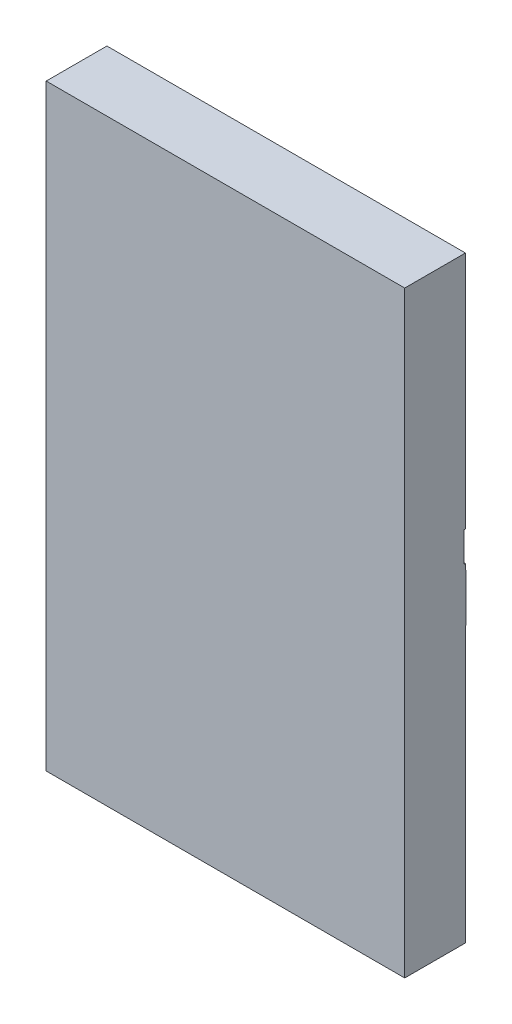
from build123d import *

# Parameters (mm, degrees)
SKETCH1_W           = 3
SKETCH1_H           = 5
BASE_EXTRUDE_DEPTH  = 0.508
SKETCH2_W           = 0.01
SKETCH2_H           = 0.25
CUT_EXTRUDE1_DEPTH  = 4
SKETCH3_W           = 0.003
SKETCH3_H           = 0.4
BOSS_EXTRUDE2_DEPTH = 3
SKETCH16_W          = 2
SKETCH16_H          = 0.5
BOSS_EXTRUDE3_DEPTH = 0.097
SKETCH17_W          = 0.005
SKETCH17_H          = 0.01
CUT_EXTRUDE2_DEPTH  = 4


with BuildPart() as part:
    # Sketch1 → Base-Extrude (new body)
    with BuildSketch(Plane.XY):
        with Locations((1.5, 2.5)):
            Rectangle(SKETCH1_W, SKETCH1_H)
    extrude(amount=BASE_EXTRUDE_DEPTH)

    # Sketch2 → Cut-Extrude1 (cut, through all)
    with BuildSketch(Plane(origin=(3, 0, 0), x_dir=(0, 0, -1), z_dir=(1, 0, 0))):
        with Locations((-0.005, 2.875)):
            Rectangle(SKETCH2_W, SKETCH2_H)
    extrude(amount=-CUT_EXTRUDE1_DEPTH, mode=Mode.SUBTRACT)

    # Sketch3 → Boss-Extrude2 (add)
    with BuildSketch(Plane(origin=(3, 0, 0), x_dir=(0, 0, -1), z_dir=(1, 0, 0))):
        with Locations((0.0015, 2.5)):
            Rectangle(SKETCH3_W, SKETCH3_H)
    extrude(amount=-BOSS_EXTRUDE2_DEPTH)

    # Sketch16 → Boss-Extrude3 (add)
    with BuildSketch(Plane(origin=(0, 0, -0.003), x_dir=(-1, 0, 0), z_dir=(0, 0, -1))):
        with Locations((-1.001, 2.5)):
            Rectangle(SKETCH16_W, SKETCH16_H)
    extrude(amount=BOSS_EXTRUDE3_DEPTH)

    # Sketch17 → Cut-Extrude2 (cut, through all)
    with BuildSketch(Plane.ZY):
        with Locations((-0.0975, 2.5)):
            Rectangle(SKETCH17_W, SKETCH17_H)
    extrude(amount=-CUT_EXTRUDE2_DEPTH, mode=Mode.SUBTRACT)


solid = part.part
